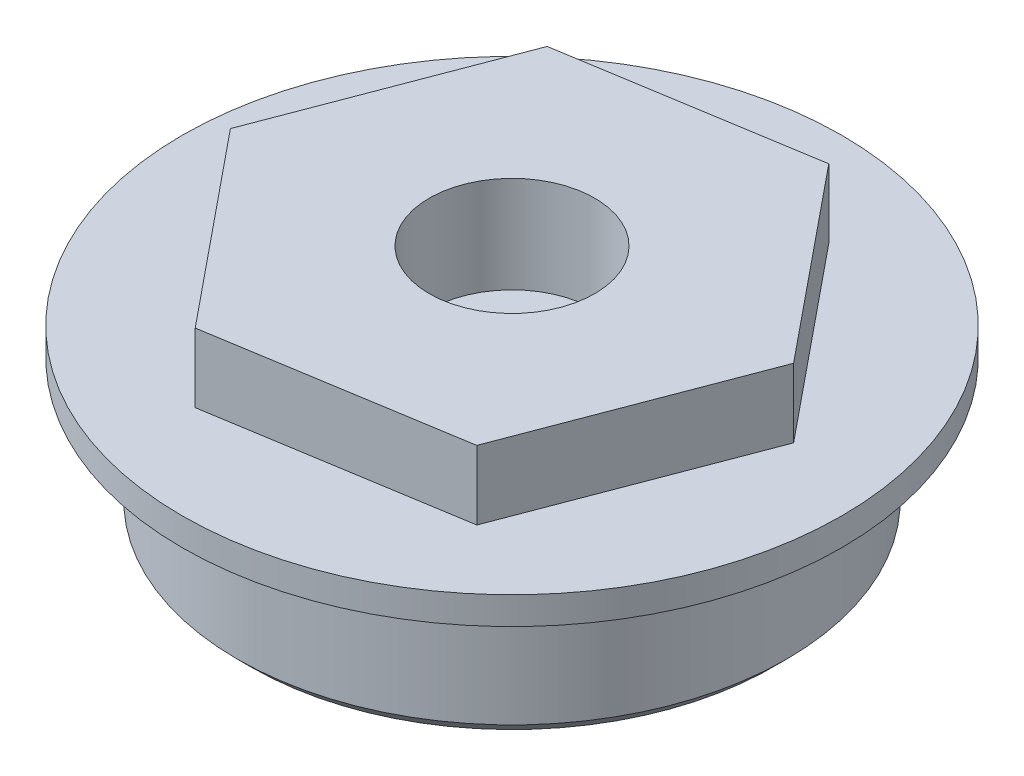
from build123d import *

# Parameters (mm, degrees)
ESQUISSE1_R             = 9.95
BOSS_EXTRU_1_DEPTH      = 6
BOSS_EXTRU_2_DEPTH      = 2.5
ESQUISSE3_R             = 11.95
ESQUISSE3_R_2           = 9.95
BOSS_EXTRU_3_DEPTH      = 1
ESQUISSE4_R             = 1.5
ENL_V_MAT_EXTRU_1_DEPTH = 5
ESQUISSE5_R             = 1.75
ENL_V_MAT_EXTRU_2_DEPTH = 9.5
ESQUISSE6_R             = 3
ENL_V_MAT_EXTRU_3_DEPTH = 3.5
CHANFREIN1_SIZE         = 0.5


with BuildPart() as part:
    # Esquisse1 → Boss.-Extru.1 (new body)
    with BuildSketch(Plane(origin=(0, 0, 0), x_dir=(1, 0, 0), z_dir=(0, 1, 0))):
        Circle(ESQUISSE1_R)
    extrude(amount=BOSS_EXTRU_1_DEPTH)

    # Esquisse2 → Boss.-Extru.2 (add)
    with BuildSketch(Plane(origin=(0, 6, 0), x_dir=(1, 0, 0), z_dir=(0, 1, 0))):
        Polygon((-3.162738548, -8.319079569), (5.623164969, -6.898551713), (8.785903517, 1.420527856), (3.162738548, 8.319079569), (-5.623164969, 6.898551713), (-8.785903517, -1.420527856), align=None)
    extrude(amount=BOSS_EXTRU_2_DEPTH)

    # Esquisse3 → Boss.-Extru.3 (add)
    with BuildSketch(Plane(origin=(0, 6, 0), x_dir=(1, 0, 0), z_dir=(0, 1, 0))):
        Circle(ESQUISSE3_R)
        Circle(ESQUISSE3_R_2, mode=Mode.SUBTRACT)
    extrude(amount=-BOSS_EXTRU_3_DEPTH)

    # Esquisse4 → Enlèv. mat.-Extru.1 (cut)
    with BuildSketch(Plane.XZ):
        with Locations((0, 6)):
            Circle(ESQUISSE4_R)
        with Locations((6, 0)):
            Circle(ESQUISSE4_R)
        with Locations((0, -6)):
            Circle(ESQUISSE4_R)
        with Locations((-6, 0)):
            Circle(ESQUISSE4_R)
    extrude(amount=-ENL_V_MAT_EXTRU_1_DEPTH, mode=Mode.SUBTRACT)

    # Esquisse5 → Enlèv. mat.-Extru.2 (cut, through all)
    with BuildSketch(Plane.XZ):
        Circle(ESQUISSE5_R)
    extrude(amount=-ENL_V_MAT_EXTRU_2_DEPTH, mode=Mode.SUBTRACT)

    # Esquisse6 → Enlèv. mat.-Extru.3 (cut)
    with BuildSketch(Plane(origin=(0, 8.5, 0), x_dir=(1, 0, 0), z_dir=(0, 1, 0))):
        Circle(ESQUISSE6_R)
    extrude(amount=-ENL_V_MAT_EXTRU_3_DEPTH, mode=Mode.SUBTRACT)

    # Chanfrein1
    chanfrein1_edges = [part.edges().sort_by_distance(p)[0] for p in [
        (-9.95, 0, 0),
    ]]
    chamfer(chanfrein1_edges, length=CHANFREIN1_SIZE)


solid = part.part
